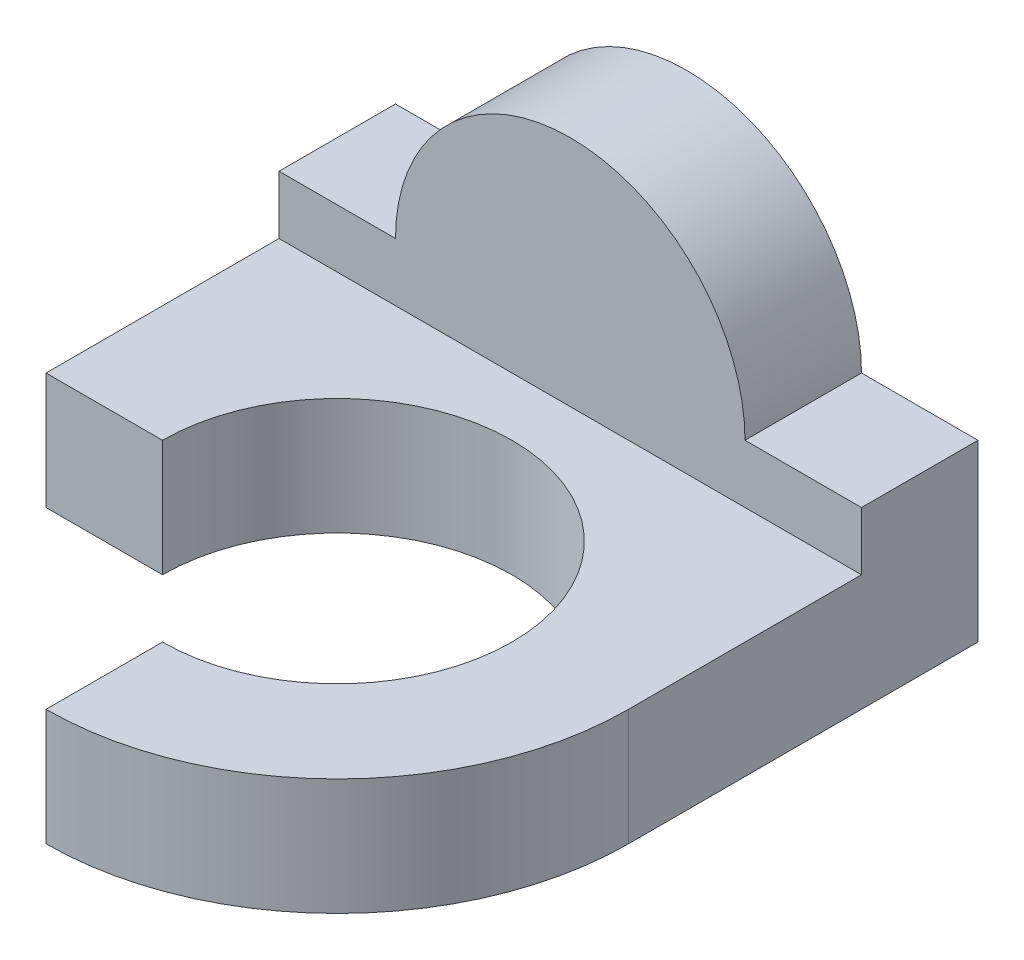
from build123d import *

# Parameters (mm, degrees)
SKETCH1_W           = 100
SKETCH1_H           = 30
BOSS_EXTRUDE1_DEPTH = 110
SKETCH2_W           = 90
SKETCH2_H           = 10
CUT_EXTRUDE1_DEPTH  = 110
BOSS_EXTRUDE2_DEPTH = 20
CUT_EXTRUDE2_DEPTH  = 20
SKETCH5_W           = 50
SKETCH5_H           = 50
CUT_EXTRUDE3_DEPTH  = 20
CUT_EXTRUDE4_DEPTH  = 20


with BuildPart() as part:
    # Sketch1 → Boss-Extrude1 (new body)
    with BuildSketch(Plane.XY):
        with Locations((50, 15)):
            Rectangle(SKETCH1_W, SKETCH1_H)
    extrude(amount=BOSS_EXTRUDE1_DEPTH)

    # Sketch2 → Cut-Extrude1 (cut)
    with BuildSketch(Plane.ZY):
        with Locations((65, 25)):
            Rectangle(SKETCH2_W, SKETCH2_H)
    extrude(amount=-CUT_EXTRUDE1_DEPTH, mode=Mode.SUBTRACT)

    # Sketch3 → Boss-Extrude2 (add)
    with BuildSketch(Plane.XY.offset(20)):
        with BuildLine():
            Line((20, 30), (80, 30))
            ThreePointArc((80, 30), (50, 60), (20, 30))
        make_face()
    extrude(amount=-BOSS_EXTRUDE2_DEPTH)

    # Sketch4 → Cut-Extrude2 (cut)
    with BuildSketch(Plane(origin=(0, 20, 0), x_dir=(1, 0, 0), z_dir=(0, 1, 0))):
        with BuildLine():
            Line((50, -110), (100, -110))
            Line((100, -110), (100, -60))
            ThreePointArc((100, -60), (85.355339059, -95.355339059), (50, -110))
        make_face()
    extrude(amount=-CUT_EXTRUDE2_DEPTH, mode=Mode.SUBTRACT)

    # Sketch5 → Cut-Extrude3 (cut)
    with BuildSketch(Plane(origin=(0, 20, 0), x_dir=(1, 0, 0), z_dir=(0, 1, 0))):
        with Locations((25, -85)):
            Rectangle(SKETCH5_W, SKETCH5_H)
    extrude(amount=-CUT_EXTRUDE3_DEPTH, mode=Mode.SUBTRACT)

    # Sketch6 → Cut-Extrude4 (cut)
    with BuildSketch(Plane(origin=(0, 20, 0), x_dir=(1, 0, 0), z_dir=(0, 1, 0))):
        with BuildLine():
            Line((20, -60), (50, -60))
            Line((50, -60), (50, -90))
            ThreePointArc((50, -90), (71.213203436, -38.786796564), (20, -60))
        make_face()
    extrude(amount=-CUT_EXTRUDE4_DEPTH, mode=Mode.SUBTRACT)


solid = part.part
